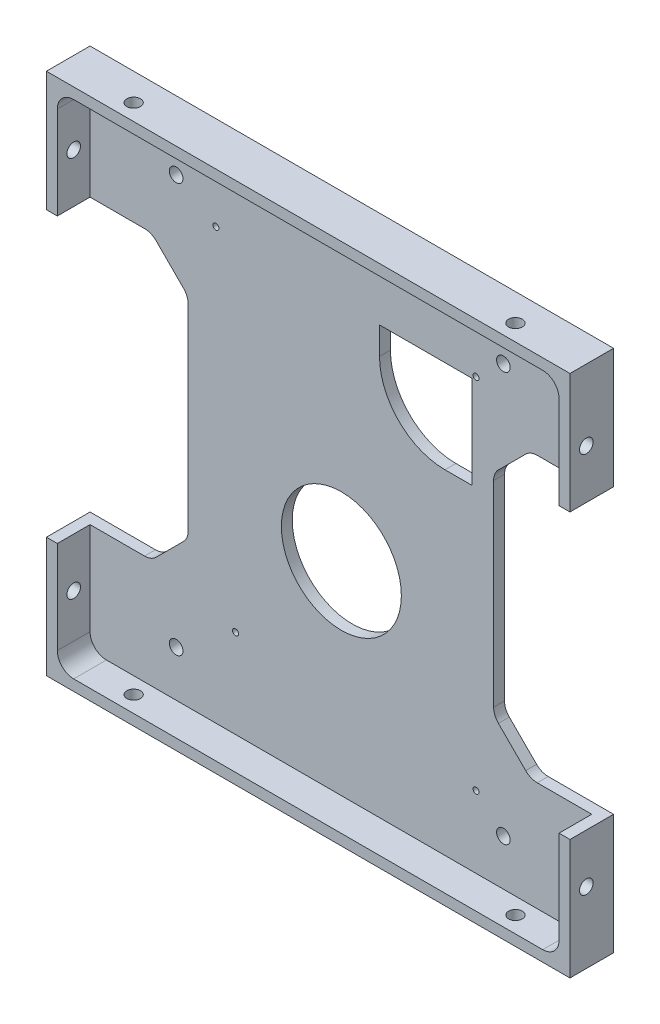
from build123d import *

# Parameters (mm, degrees)
SKETCH1_W                      = 96
SKETCH1_H                      = 96
BOSS_EXTRUDE1_DEPTH            = 8
SKETCH2_W                      = 92
SKETCH2_H                      = 92
COMPONENT_PLATFORM_DEPTH       = 6
CABLE_SLOTS_DEPTH              = 6
INNER_CORNER_FILLETS_R         = 3
M3X0_5_TAPPED_HOLE1_AT_2_COUNT = 2
M3X0_5_TAPPED_HOLE1_AT_2_PITCH = 70
M3X0_5_TAPPED_HOLE2_AT_2_COUNT = 2
M3X0_5_TAPPED_HOLE2_AT_2_PITCH = 70
M1_4X0_3_TAPPED_HOLE1_D        = 1.1
M1_4X0_3_TAPPED_HOLE1_DEPTH    = 3.7
M1_4X0_3_TAPPED_HOLE1_TIP      = 0.33047334
SKETCH29_R                     = 11
HDD_EXTRUSION_CUTOUT_DEPTH     = 10
HDD_EXTRUSION_CUTOUT_2_DEPTH   = 10
M3X0_5_TAPPED_HOLE3_D          = 2.5
M3X0_5_TAPPED_HOLE3_DEPTH      = 10
M3X0_5_TAPPED_HOLE3_TIP        = 0.751075774


with BuildPart() as part:
    # Sketch1 → Boss-Extrude1 (new body)
    with BuildSketch(Plane.XY):
        Rectangle(SKETCH1_W, SKETCH1_H)
    extrude(amount=BOSS_EXTRUDE1_DEPTH)

    # Sketch2 → Component Platform (cut)
    with BuildSketch(Plane.XY.offset(8)):
        Rectangle(SKETCH2_W, SKETCH2_H)
    extrude(amount=-COMPONENT_PLATFORM_DEPTH, mode=Mode.SUBTRACT)

    # Sketch3 → Cable Slots (cut, symmetric)
    with BuildSketch(Plane.XY.offset(2)):
        with BuildLine():
            Line((-33.878679656, -25.121320344), (-28.878679656, -20.121320344))
            ThreePointArc((-28.878679656, -20.121320344), (-28.228361402, -19.148050297), (-28, -18))
            Line((-28, -18), (-28, 18))
            ThreePointArc((-28, 18), (-28.228361402, 19.148050297), (-28.878679656, 20.121320344))
            Line((-28.878679656, 20.121320344), (-33.878679656, 25.121320344))
            ThreePointArc((-33.878679656, 25.121320344), (-34.851949703, 25.771638598), (-36, 26))
            Line((-36, 26), (-48, 26))
            Line((-48, 26), (-48, -26))
            Line((-48, -26), (-36, -26))
            ThreePointArc((-36, -26), (-34.851949703, -25.771638598), (-33.878679656, -25.121320344))
        make_face()
        with BuildLine():
            Line((48, -26), (48, 26))
            Line((48, 26), (36, 26))
            ThreePointArc((36, 26), (34.851949703, 25.771638598), (33.878679656, 25.121320344))
            Line((33.878679656, 25.121320344), (28.878679656, 20.121320344))
            ThreePointArc((28.878679656, 20.121320344), (28.228361402, 19.148050297), (28, 18))
            Line((28, 18), (28, -18))
            ThreePointArc((28, -18), (28.228361402, -19.148050297), (28.878679656, -20.121320344))
            Line((28.878679656, -20.121320344), (33.878679656, -25.121320344))
            ThreePointArc((33.878679656, -25.121320344), (34.851949703, -25.771638598), (36, -26))
            Line((36, -26), (48, -26))
        make_face()
    extrude(amount=CABLE_SLOTS_DEPTH, both=True, mode=Mode.SUBTRACT)

    # Inner Corner Fillets
    inner_corner_fillets_edges = [part.edges().sort_by_distance(p)[0] for p in [
        (-46, -46, 5),
        (-46, 46, 5),
        (46, 46, 5),
        (46, -46, 5),
    ]]
    fillet(inner_corner_fillets_edges, radius=INNER_CORNER_FILLETS_R)

    # Sketch14 → M3x0.5 Tapped Hole1 (revolve, cut)
    with BuildSketch(Plane(origin=(48, -35, 5), x_dir=(0, 0, -1), z_dir=(0, 1, 0))):
        Polygon((0, 0), (0, 10.751075774), (1.25, 10), (1.25, 0), align=None)
    m3x0_5_tapped_hole1 = revolve(axis=Axis((54.35, -35, 5), (-1, 0, 0)), mode=Mode.SUBTRACT)

    # M3x0.5 Tapped Hole1 at 2: M3x0.5 Tapped Hole1 ×2
    with Locations(*[(0, i * M3X0_5_TAPPED_HOLE1_AT_2_PITCH, 0) for i in range(1, M3X0_5_TAPPED_HOLE1_AT_2_COUNT)]):
        add(m3x0_5_tapped_hole1, mode=Mode.SUBTRACT)

    # Sketch16 → M3x0.5 Tapped Hole2 (revolve, cut)
    with BuildSketch(Plane(origin=(35, 48, 5), x_dir=(0, 0, 1), z_dir=(1, 0, 0))):
        Polygon((0, 0), (0, 10.751075774), (1.25, 10), (1.25, 0), align=None)
    m3x0_5_tapped_hole2 = revolve(axis=Axis((35, 54.35, 5), (0, -1, 0)), mode=Mode.SUBTRACT)

    # M3x0.5 Tapped Hole2 at 2: M3x0.5 Tapped Hole2 ×2
    with Locations(*[(-i * M3X0_5_TAPPED_HOLE2_AT_2_PITCH, 0, 0) for i in range(1, M3X0_5_TAPPED_HOLE2_AT_2_COUNT)]):
        add(m3x0_5_tapped_hole2, mode=Mode.SUBTRACT)

    # Mirror1: M3x0.5 Tapped Hole1 across plane
    add(m3x0_5_tapped_hole1.mirror(Plane(origin=(0, 0, 0), x_dir=(0, 0, 1), z_dir=(1, 0, 0))), mode=Mode.SUBTRACT)

    # Mirror1 copy 1 sketch → Mirror1 copy 1 (revolve, cut)
    with BuildSketch(Plane(origin=(-48, 35, 5), x_dir=(0, 0, -1), z_dir=(0, 1, 0))):
        Polygon((0, 0), (0, -10.751075774), (1.25, -10), (1.25, 0), align=None)
    revolve(axis=Axis((-54.35, 35, 5), (-1, 0, 0)), mode=Mode.SUBTRACT)

    # Mirror2: M3x0.5 Tapped Hole2 across plane
    add(m3x0_5_tapped_hole2.mirror(Plane(origin=(0, 0, 0), x_dir=(0, 0, 1), z_dir=(0, -1, 0))), mode=Mode.SUBTRACT)

    # Mirror2 copy 1 sketch → Mirror2 copy 1 (revolve, cut)
    with BuildSketch(Plane(origin=(-35, -48, 5), x_dir=(0, 0, 1), z_dir=(1, 0, 0))):
        Polygon((0, 0), (0, -10.751075774), (1.25, -10), (1.25, 0), align=None)
    revolve(axis=Axis((-35, -54.35, 5), (0, -1, 0)), mode=Mode.SUBTRACT)

    # M1.4x0.3 Tapped Hole1
    with Locations(Plane.XY.offset(2)):
        with Locations((-19.31998517, -29.75), (24.78001483, -32.85), (24.78001483, 32.85), (-22.91998517, 32.85)):
            Hole(M1_4X0_3_TAPPED_HOLE1_D / 2, depth=M1_4X0_3_TAPPED_HOLE1_DEPTH)
            with Locations((0, 0, -(M1_4X0_3_TAPPED_HOLE1_DEPTH + M1_4X0_3_TAPPED_HOLE1_TIP / 2))):  # 118° drill point
                Cone(0, M1_4X0_3_TAPPED_HOLE1_D / 2, M1_4X0_3_TAPPED_HOLE1_TIP, mode=Mode.SUBTRACT)

    # Sketch29 → HDD Extrusion Cutout (cut)
    with BuildSketch(Plane(origin=(0, 0, 0), x_dir=(-1, 0, 0), z_dir=(0, 0, -1))):
        with Locations((-0.08192631, -8.74785827)):
            Circle(SKETCH29_R)
    extrude(amount=-HDD_EXTRUSION_CUTOUT_DEPTH, mode=Mode.SUBTRACT)

    # Sketch9 → HDD Extrusion Cutout 2 (cut)
    with BuildSketch(Plane.XY.offset(2)):
        with BuildLine():
            Line((24.08001483, 32.25), (24.08001483, 15.25))
            Line((24.08001483, 15.25), (19.08001483, 15.25))
            ThreePointArc((19.08001483, 15.25), (10.594733456, 18.764718626), (7.08001483, 27.25))
            Line((7.08001483, 27.25), (7.08001483, 32.25))
            Line((7.08001483, 32.25), (24.08001483, 32.25))
        make_face()
    extrude(amount=-HDD_EXTRUSION_CUTOUT_2_DEPTH, mode=Mode.SUBTRACT)

    # M3x0.5 Tapped Hole3
    with Locations(Plane.XY.offset(2)):
        with Locations((-30.20998517, -37.56), (29.79001483, -37.56), (29.79001483, 37.44), (-30.20998517, 37.44)):
            Hole(M3X0_5_TAPPED_HOLE3_D / 2, depth=M3X0_5_TAPPED_HOLE3_DEPTH)
            with Locations((0, 0, -(M3X0_5_TAPPED_HOLE3_DEPTH + M3X0_5_TAPPED_HOLE3_TIP / 2))):  # 118° drill point
                Cone(0, M3X0_5_TAPPED_HOLE3_D / 2, M3X0_5_TAPPED_HOLE3_TIP, mode=Mode.SUBTRACT)


solid = part.part
